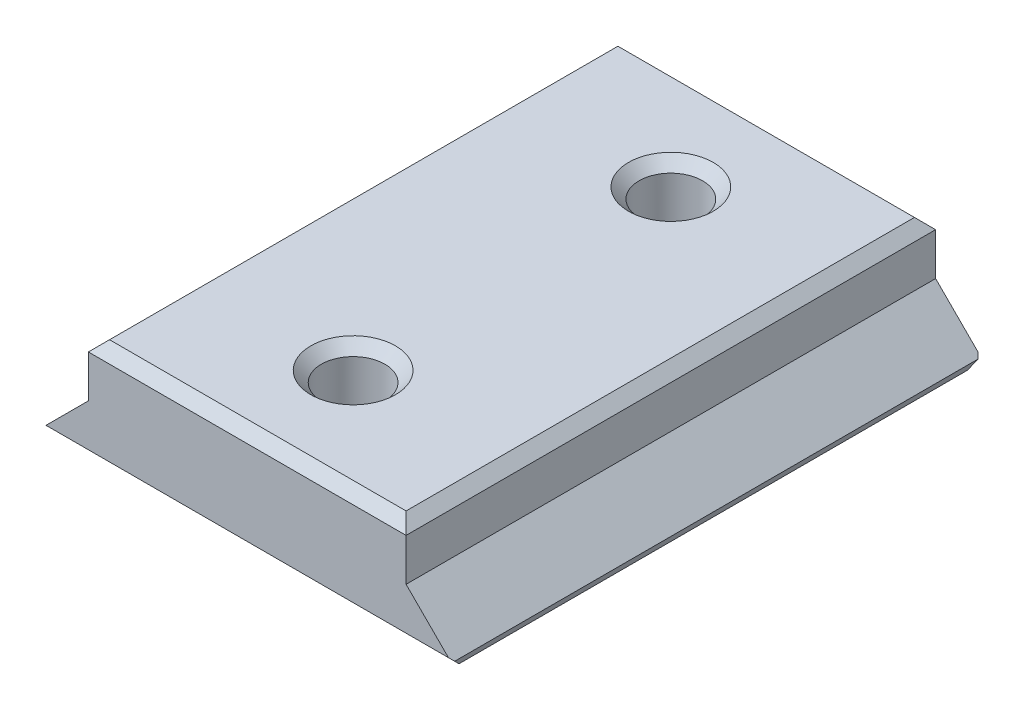
from build123d import *

# Parameters (mm, degrees)
EXTRUDE_1_DEPTH     = 50
SKETCH_4_R          = 3
CUT_EXTRUDE_1_DEPTH = 50
CHAMFER_1_SIZE      = 5
CHAMFER_2_SIZE      = 5
CHAMFER_4_SIZE      = 1
CHAMFER_5_SIZE      = 1
CHAMFER_6_SIZE      = 1


with BuildPart() as part:
    # 草图2 → 凸台-拉伸1 (new body)
    with BuildSketch(Plane.XY):
        Polygon((0, 0), (15, 0), (15, -5), (20, -10), (-20, -10), (-15, -5), (-15, 0), align=None)
    extrude(amount=EXTRUDE_1_DEPTH)

    # 草图4 → 切除-拉伸1 (cut)
    with BuildSketch(Plane.XZ.offset(10)):
        with Locations((0, 40)):
            Circle(SKETCH_4_R)
        with Locations((0, 10)):
            Circle(SKETCH_4_R)
    extrude(amount=-CUT_EXTRUDE_1_DEPTH, mode=Mode.SUBTRACT)

    # 倒角1
    chamfer_1_edges = [part.edges().sort_by_distance(p)[0] for p in [
        (-3, -10, 10),
    ]]
    chamfer(chamfer_1_edges, length=CHAMFER_1_SIZE)

    # 倒角2
    chamfer_2_edges = [part.edges().sort_by_distance(p)[0] for p in [
        (-3, -10, 40),
    ]]
    chamfer(chamfer_2_edges, length=CHAMFER_2_SIZE)

    # 倒角4
    chamfer_4_edges = [part.edges().sort_by_distance(p)[0] for p in [
        (15, 0, 25),
        (-15, 0, 25),
        (-3, 0, 40),
        (-3, 0, 10),
        (0, 0, 50),
        (0, 0, 0),
    ]]
    chamfer(chamfer_4_edges, length=CHAMFER_4_SIZE)

    # 倒角5
    chamfer_5_edges = [part.edges().sort_by_distance(p)[0] for p in [
        (20, -10, 25),
        (-20, -10, 25),
    ]]
    chamfer(chamfer_5_edges, length=CHAMFER_5_SIZE)

    # 倒角6
    chamfer_6_edges = [part.edges().sort_by_distance(p)[0] for p in [
        (0, -10, 0),
        (0, -10, 50),
    ]]
    chamfer(chamfer_6_edges, length=CHAMFER_6_SIZE)


solid = part.part
